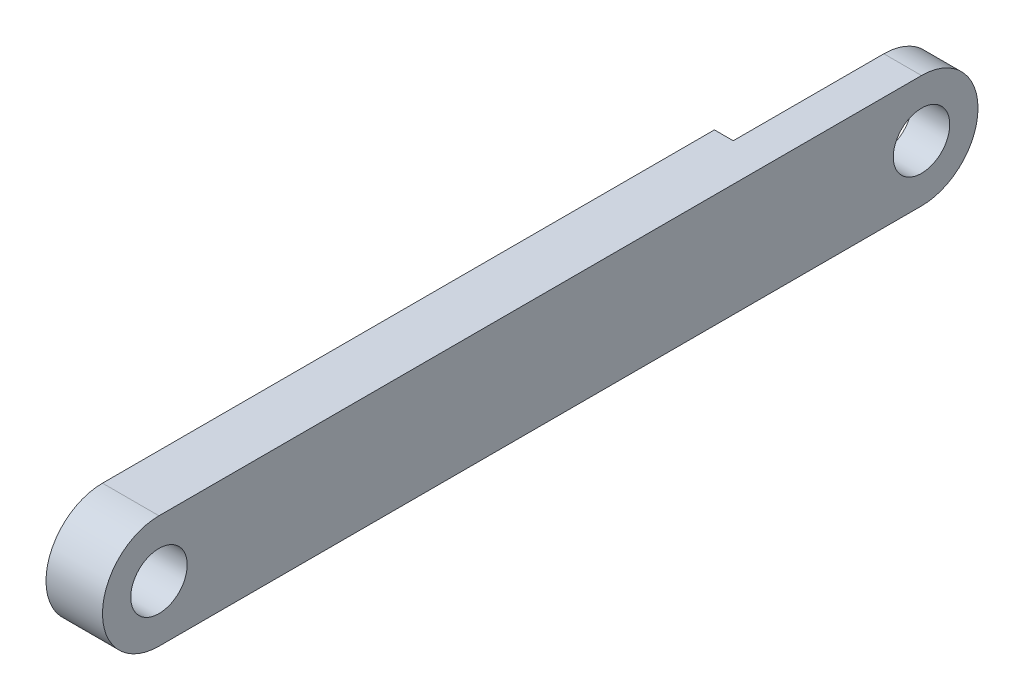
from build123d import *

# Parameters (mm, degrees)
SKETCH1_R           = 1.5
BOSS_EXTRUDE1_DEPTH = 3
SKETCH3_W           = 11
SKETCH3_H           = 6
CUT_EXTRUDE2_DEPTH  = 1


with BuildPart() as part:
    # Sketch1 → Boss-Extrude1 (new body)
    with BuildSketch(Plane(origin=(0, 0, 0), x_dir=(0, 0, -1), z_dir=(1, 0, 0))):
        with BuildLine():
            Line((0, 3), (40.5, 3))
            ThreePointArc((40.5, 3), (43.5, 0), (40.5, -3))
            Line((40.5, -3), (0, -3))
            ThreePointArc((0, -3), (-3, 0), (0, 3))
        make_face()
        Circle(SKETCH1_R, mode=Mode.SUBTRACT)
        with Locations((40.5, 0)):
            Circle(SKETCH1_R, mode=Mode.SUBTRACT)
    extrude(amount=BOSS_EXTRUDE1_DEPTH)

    # Sketch3 → Cut-Extrude2 (cut)
    with BuildSketch(Plane.ZY):
        with Locations((-38, 0)):
            Rectangle(SKETCH3_W, SKETCH3_H)
    extrude(amount=-CUT_EXTRUDE2_DEPTH, mode=Mode.SUBTRACT)


solid = part.part
